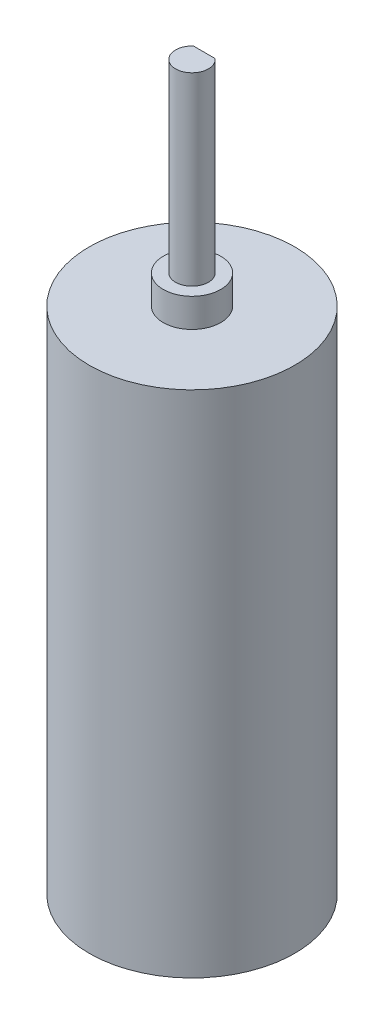
from build123d import *

# Parameters (mm, degrees)
SKETCH_1_R          = 12.5
EXTRUDE_1_DEPTH     = 62
SKETCH_2_R          = 3.5
EXTRUDE_2_DEPTH     = 3.5
SKETCH_3_R          = 2
EXTRUDE_3_DEPTH     = 22.5
CUT_EXTRUDE_1_DEPTH = 18.5


with BuildPart() as part:
    # 草图1 → 凸台-拉伸1 (new body)
    with BuildSketch(Plane(origin=(0, 0, 0), x_dir=(1, 0, 0), z_dir=(0, 1, 0))):
        Circle(SKETCH_1_R)
    extrude(amount=EXTRUDE_1_DEPTH)

    # 草图2 → 凸台-拉伸2 (add)
    with BuildSketch(Plane(origin=(0, 62, 0), x_dir=(1, 0, 0), z_dir=(0, 1, 0))):
        Circle(SKETCH_2_R)
    extrude(amount=EXTRUDE_2_DEPTH)

    # 草图3 → 凸台-拉伸3 (add)
    with BuildSketch(Plane(origin=(0, 65.5, 0), x_dir=(1, 0, 0), z_dir=(0, 1, 0))):
        Circle(SKETCH_3_R)
    extrude(amount=EXTRUDE_3_DEPTH)

    # 草图4 → 切除-拉伸1 (cut)
    with BuildSketch(Plane(origin=(0, 88, 0), x_dir=(1, 0, 0), z_dir=(0, 1, 0))):
        Polygon((-50.671161076, 1.5), (-1.322875656, 1.5), (1.322875656, 1.5), (50.671161076, 1.5), (50.671161076, 100.196570842), (-50.671161076, 100.196570842), align=None)
    extrude(amount=-CUT_EXTRUDE_1_DEPTH, mode=Mode.SUBTRACT)


solid = part.part
